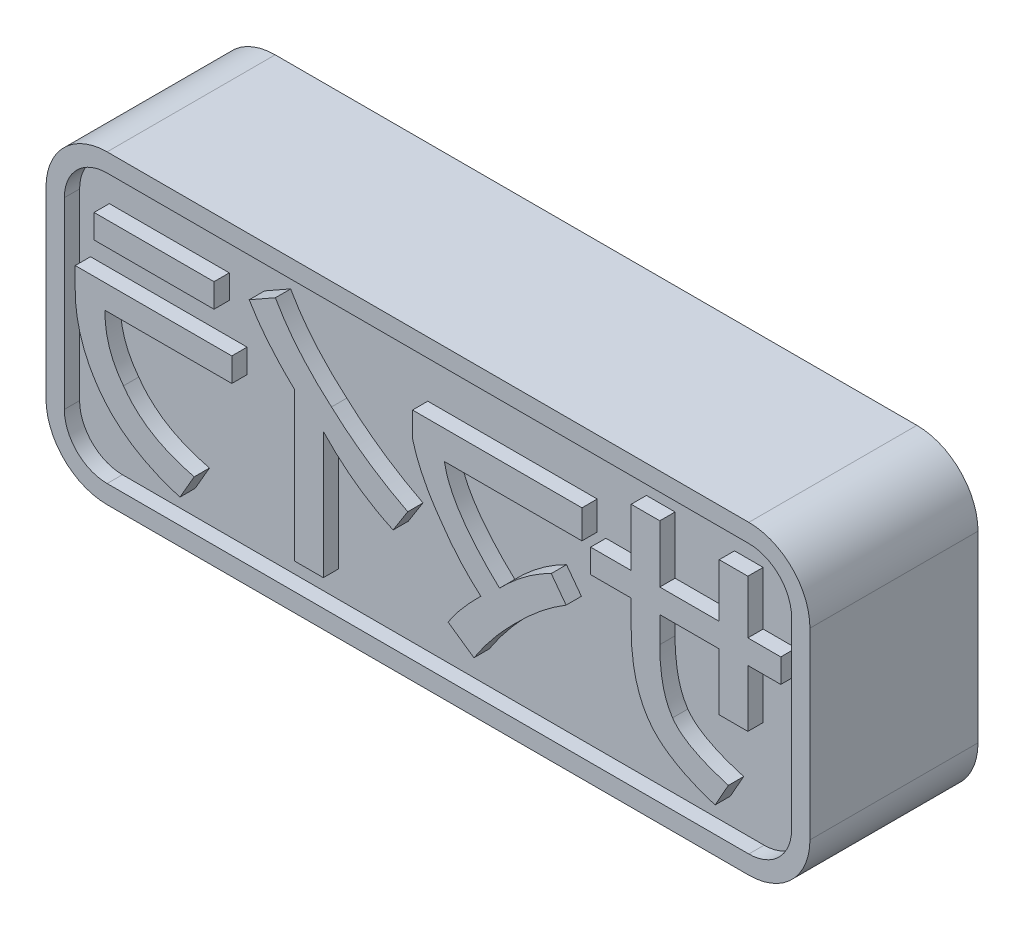
from build123d import *

# Parameters (mm, degrees)
BOSS_EXTRUDE1_DEPTH = 5
BOSS_EXTRUDE2_DEPTH = 0.5
SKETCH3_W           = 3.925243157
SKETCH3_H           = 0.7806506
BOSS_EXTRUDE3_DEPTH = 0.5
SKETCH4_W           = 4
SKETCH4_H           = 4
CUT_EXTRUDE1_DEPTH  = 4


with BuildPart() as part:
    # Sketch1 → Boss-Extrude1 (new body)
    with BuildSketch(Plane.XY):
        with BuildLine():
            Line((-10.5, 5), (10.5, 5))
            ThreePointArc((10.5, 5), (11.914213562, 4.414213562), (12.5, 3))
            Line((12.5, 3), (12.5, -3))
            ThreePointArc((12.5, -3), (11.914213562, -4.414213562), (10.5, -5))
            Line((10.5, -5), (-10.5, -5))
            ThreePointArc((-10.5, -5), (-11.914213562, -4.414213562), (-12.5, -3))
            Line((-12.5, -3), (-12.5, 3))
            ThreePointArc((-12.5, 3), (-11.914213562, 4.414213562), (-10.5, 5))
        make_face()
    extrude(amount=BOSS_EXTRUDE1_DEPTH)

    # Sketch2 → Boss-Extrude2 (add)
    with BuildSketch(Plane.XY.offset(5)):
        with BuildLine():
            Line((10.5, 5), (-10.5, 5))
            ThreePointArc((-10.5, 5), (-11.914213562, 4.414213562), (-12.5, 3))
            Line((-12.5, 3), (-12.5, -3))
            ThreePointArc((-12.5, -3), (-11.914213562, -4.414213562), (-10.5, -5))
            Line((-10.5, -5), (10.5, -5))
            ThreePointArc((10.5, -5), (11.914213562, -4.414213562), (12.5, -3))
            Line((12.5, -3), (12.5, 3))
            ThreePointArc((12.5, 3), (11.914213562, 4.414213562), (10.5, 5))
        make_face()
        with BuildLine():
            Line((10.5, 4.4), (-10.5, 4.4))
            ThreePointArc((-10.5, 4.4), (-11.489949494, 3.989949494), (-11.9, 3))
            Line((-11.9, 3), (-11.9, -3))
            ThreePointArc((-11.9, -3), (-11.489949494, -3.989949494), (-10.5, -4.4))
            Line((-10.5, -4.4), (10.5, -4.4))
            ThreePointArc((10.5, -4.4), (11.489949494, -3.989949494), (11.9, -3))
            Line((11.9, -3), (11.9, 3))
            ThreePointArc((11.9, 3), (11.489949494, 3.989949494), (10.5, 4.4))
        make_face(mode=Mode.SUBTRACT)
    extrude(amount=BOSS_EXTRUDE2_DEPTH)

    # Sketch3 → Boss-Extrude3 (add)
    with BuildSketch(Plane.XY.offset(5)):
        with BuildLine():
            Line((6.649827221, 1.709613878), (5.323087704, 1.709613878))
            Line((5.323087704, 1.709613878), (5.323087704, 0.928963278))
            Line((5.323087704, 0.928963278), (6.649827221, 0.928963278))
            Line((6.649827221, 0.928963278), (6.649827221, 0.077455503))
            add(Edge.make_bspline(
                [(6.649827221, 0.077455503), (6.651376704, -0.04109447), (6.654389008, -0.271563805), (6.680326701, -0.60728573), (6.722849081, -0.922577431), (6.780511342, -1.218488728), (6.857426325, -1.494254078), (6.951751475, -1.7497529), (7.059867372, -1.987100715), (7.150329181, -2.13059508), (7.194694462, -2.200969174)],
                knots=[0, 0, 0, 0, 0.00035561, 0.000691331, 0.00100941, 0.001309617, 0.001595066, 0.001867173, 0.002126226, 0.00237555, 0.00237555, 0.00237555, 0.00237555], degree=3))
            add(Edge.make_bspline(
                [(7.194694462, -2.200969174), (7.244642663, -2.271234317), (7.347224688, -2.415542633), (7.540893795, -2.610859351), (7.766322614, -2.796525633), (8.026697725, -2.970926795), (8.3188806, -3.137490143), (8.647315694, -3.290384525), (9.008785884, -3.43460474), (9.264120724, -3.518522161), (9.396153587, -3.561915603)],
                knots=[0, 0, 0, 0, 0.000258262, 0.000530411, 0.00082198, 0.001133375, 0.001469318, 0.001830002, 0.002219293, 0.002636149, 0.002636149, 0.002636149, 0.002636149], degree=3))
            Line((9.396153587, -3.561915603), (9.83107004, -2.788595056))
            add(Edge.make_bspline(
                [(9.83107004, -2.788595056), (9.717559395, -2.754529617), (9.499669347, -2.689139096), (9.190805721, -2.579792321), (8.914393277, -2.462638286), (8.669226473, -2.340898436), (8.454916696, -2.215006455), (8.273973509, -2.080806813), (8.121241957, -1.942939679), (8.042367052, -1.838964249), (8.004665273, -1.789264554)],
                knots=[0, 0, 0, 0, 0.000355505, 0.000682413, 0.000982388, 0.001255563, 0.001503211, 0.001726781, 0.001930768, 0.002117556, 0.002117556, 0.002117556, 0.002117556], degree=3))
            add(Edge.make_bspline(
                [(8.004665273, -1.789264554), (7.97091344, -1.736591364), (7.90116179, -1.627736773), (7.816284223, -1.445481925), (7.746693078, -1.242249433), (7.68580288, -1.019368833), (7.642365255, -0.774306097), (7.609318914, -0.508888526), (7.589825389, -0.222553891), (7.587865516, -0.024788046), (7.586852275, 0.077455503)],
                knots=[0, 0, 0, 0, 0.000187522, 0.000387534, 0.000601202, 0.000831464, 0.001079945, 0.001347093, 0.001633632, 0.001940334, 0.001940334, 0.001940334, 0.001940334], degree=3))
            Line((7.586852275, 0.077455503), (7.586852275, 0.928963278))
            Line((7.586852275, 0.928963278), (9.53175956, 0.928963278))
            Line((9.53175956, 0.928963278), (9.53175956, -0.94020013))
            Line((9.53175956, -0.94020013), (10.468784615, -0.94020013))
            Line((10.468784615, -0.94020013), (10.468784615, 0.928963278))
            Line((10.468784615, 0.928963278), (11.546302344, 0.928963278))
            Line((11.546302344, 0.928963278), (11.546302344, 1.709613878))
            Line((11.546302344, 1.709613878), (10.468784615, 1.709613878))
            Line((10.468784615, 1.709613878), (10.468784615, 3.457831418))
            Line((10.468784615, 3.457831418), (9.53175956, 3.457831418))
            Line((9.53175956, 3.457831418), (9.53175956, 1.709613878))
            Line((9.53175956, 1.709613878), (7.586852275, 1.709613878))
            Line((7.586852275, 1.709613878), (7.586852275, 3.587329014))
            Line((7.586852275, 3.587329014), (6.649827221, 3.587329014))
            Line((6.649827221, 3.587329014), (6.649827221, 1.709613878))
        make_face()
        with BuildLine():
            Line((-0.505037103, 2.680845844), (-0.505037103, 1.864766657))
            add(Edge.make_bspline(
                [(-0.505037103, 1.864766657), (-0.484267586, 1.789996362), (-0.442260619, 1.63877121), (-0.36316234, 1.413323447), (-0.270101459, 1.18645249), (-0.163873315, 0.957443294), (-0.042059676, 0.727726438), (0.092279384, 0.495778435), (0.239848847, 0.261698262), (0.347810416, 0.108748512), (0.402667741, 0.031031837)],
                knots=[0, 0, 0, 0, 0.000232754, 0.000470752, 0.000716221, 0.000968188, 0.001227762, 0.001495974, 0.001772197, 0.002057539, 0.002057539, 0.002057539, 0.002057539], degree=3))
            add(Edge.make_bspline(
                [(0.402667741, 0.031031837), (0.49958699, -0.109358468), (0.692054565, -0.38815326), (1.01547789, -0.777548328), (1.356949717, -1.145524269), (1.605456588, -1.367994782), (1.729407258, -1.478958995)],
                knots=[0, 0, 0, 0, 0.000511545, 0.001015854, 0.001517132, 0.002015972, 0.002015972, 0.002015972, 0.002015972], degree=3))
            add(Edge.make_bspline(
                [(1.729407258, -1.478958995), (1.670151814, -1.538207794), (1.554682383, -1.653664276), (1.389667665, -1.825538932), (1.237833658, -1.992592168), (1.096933895, -2.152912464), (0.970214915, -2.309628262), (0.854746069, -2.45993165), (0.751886981, -2.604935761), (0.69021137, -2.701614191), (0.660441257, -2.748279767)],
                knots=[0, 0, 0, 0, 0.000251383, 0.000489864, 0.000714705, 0.000928582, 0.001130066, 0.001319189, 0.001497139, 0.001663179, 0.001663179, 0.001663179, 0.001663179], degree=3))
            Line((0.660441257, -2.748279767), (1.504618979, -3.335905649))
            add(Edge.make_bspline(
                [(1.504618979, -3.335905649), (1.597431175, -3.196669156), (1.784965099, -2.915331497), (2.100880543, -2.509948678), (2.442766783, -2.109416968), (2.691019742, -1.854692366), (2.816698391, -1.725737432)],
                knots=[0, 0, 0, 0, 0.000501847, 0.001014019, 0.001540744, 0.002080809, 0.002080809, 0.002080809, 0.002080809], degree=3))
            add(Edge.make_bspline(
                [(2.816698391, -1.725737432), (2.885903369, -1.654856266), (3.022721921, -1.514723882), (3.233111214, -1.314405094), (3.444953238, -1.125033935), (3.656563471, -0.944846947), (3.871708683, -0.778290181), (4.084531698, -0.618039734), (4.301380835, -0.471677402), (4.448158901, -0.38061975), (4.520935616, -0.335470792)],
                knots=[0, 0, 0, 0, 0.000297171, 0.000587509, 0.000871279, 0.001149556, 0.001421071, 0.001687399, 0.001948646, 0.00220557, 0.00220557, 0.00220557, 0.00220557], degree=3))
            Line((4.520935616, -0.335470792), (4.034708795, 0.316903887))
            add(Edge.make_bspline(
                [(4.034708795, 0.316903887), (3.960953536, 0.280292652), (3.812480075, 0.206592187), (3.595874947, 0.079191127), (3.380980234, -0.060254724), (3.167389712, -0.211308698), (2.956564018, -0.375523874), (2.749279624, -0.553511767), (2.541937549, -0.742220943), (2.408877284, -0.876870855), (2.341466649, -0.945086832)],
                knots=[0, 0, 0, 0, 0.00024696, 0.000497144, 0.000753323, 0.001015346, 0.001281716, 0.001554686, 0.001834836, 0.002122501, 0.002122501, 0.002122501, 0.002122501], degree=3))
            add(Edge.make_bspline(
                [(2.341466649, -0.945086832), (2.276016434, -0.883085452), (2.147013849, -0.760880533), (1.962205036, -0.575814487), (1.788155766, -0.393434343), (1.625466074, -0.213909636), (1.474266243, -0.03681547), (1.332913411, 0.136905176), (1.203288495, 0.308588472), (1.08669648, 0.479157297), (0.977539919, 0.644751775), (0.883510164, 0.810275163), (0.796555878, 0.970973726), (0.723892617, 1.130719051), (0.65927171, 1.286598619), (0.608325375, 1.441122312), (0.56701504, 1.592722364), (0.548571817, 1.693986077), (0.53949539, 1.74382079)],
                knots=[0, 0, 0, 0, 0.000270454, 0.000533066, 0.000784521, 0.001026702, 0.001259786, 0.001483019, 0.001698522, 0.001904899, 0.002102795, 0.002293271, 0.002475804, 0.002650721, 0.002819507, 0.002981765, 0.003138525, 0.003290426, 0.003290426, 0.003290426, 0.003290426], degree=3))
            Line((0.53949539, 1.74382079), (5.038925998, 1.74382079))
            Line((5.038925998, 1.74382079), (5.038925998, 2.680845844))
            Line((5.038925998, 2.680845844), (-0.505037103, 2.680845844))
        make_face()
        with BuildLine():
            add(Edge.make_bspline(
                [(-3.156805792, 1.442066958), (-3.25522625, 1.528869115), (-3.44955869, 1.700261074), (-3.724710935, 1.966366833), (-3.982469619, 2.234734149), (-4.221946475, 2.505257924), (-4.442354268, 2.779355028), (-4.643865171, 3.056176701), (-4.829971174, 3.333701677), (-4.93910268, 3.524761156), (-4.992983963, 3.619092575)],
                knots=[0, 0, 0, 0, 0.000393647, 0.000777261, 0.001147936, 0.001509725, 0.001860786, 0.00220264, 0.002536729, 0.002862541, 0.002862541, 0.002862541, 0.002862541], degree=3))
            Line((-4.992983963, 3.619092575), (-5.84937844, 3.134087429))
            add(Edge.make_bspline(
                [(-5.84937844, 3.134087429), (-5.804009534, 3.058345693), (-5.712030283, 2.904789684), (-5.559841151, 2.678613895), (-5.393363342, 2.452888576), (-5.214049139, 2.226795409), (-5.019919277, 2.001906345), (-4.814021153, 1.776001926), (-4.593713476, 1.550511754), (-4.438849934, 1.404081361), (-4.36015609, 1.329672819)],
                knots=[0, 0, 0, 0, 0.000264836, 0.000536919, 0.000817428, 0.001106101, 0.001402392, 0.001708508, 0.002022971, 0.002347854, 0.002347854, 0.002347854, 0.002347854], degree=3))
            Line((-4.36015609, 1.329672819), (-4.36015609, -3.530152042))
            Line((-4.36015609, -3.530152042), (-3.423131035, -3.530152042))
            Line((-3.423131035, -3.530152042), (-3.423131035, 0.613771017))
            add(Edge.make_bspline(
                [(-3.423131035, 0.613771017), (-3.338844608, 0.526605486), (-3.171213317, 0.353248151), (-2.906413817, 0.109258186), (-2.634244356, -0.120920355), (-2.352914121, -0.33503908), (-2.062185779, -0.533377152), (-1.763523465, -0.717466358), (-1.456643922, -0.887474309), (-1.245458606, -0.986951892), (-1.139819657, -1.036712489)],
                knots=[0, 0, 0, 0, 0.000363692, 0.000723322, 0.001079651, 0.001432724, 0.001783438, 0.00213503, 0.002484961, 0.002835198, 0.002835198, 0.002835198, 0.002835198], degree=3))
            Line((-1.139819657, -1.036712489), (-0.662144563, -0.280495398))
            add(Edge.make_bspline(
                [(-0.662144563, -0.280495398), (-0.777016191, -0.220218246), (-1.0059522, -0.100087531), (-1.340219824, 0.093802171), (-1.666475713, 0.29492891), (-1.983409141, 0.505102353), (-2.290472502, 0.725404632), (-2.588232721, 0.95540031), (-2.878376554, 1.192775752), (-3.064152811, 1.359110249), (-3.156805792, 1.442066958)],
                knots=[0, 0, 0, 0, 0.00038914, 0.000775545, 0.001158991, 0.001538822, 0.001916162, 0.002292469, 0.002667414, 0.003040466, 0.003040466, 0.003040466, 0.003040466], degree=3))
        make_face()
        with Locations((-8.964772954, 2.679013331)):
            Rectangle(SKETCH3_W, SKETCH3_H)
        with BuildLine():
            Line((-6.419412195, 1.256372293), (-11.543118949, 1.256372293))
            Line((-11.543118949, 1.256372293), (-11.543118949, 0.562460649))
            add(Edge.make_bspline(
                [(-11.543118949, 0.562460649), (-11.541283624, 0.455249927), (-11.537644518, 0.24267116), (-11.500082152, -0.072002736), (-11.443837031, -0.380312494), (-11.360659544, -0.681258927), (-11.257542506, -0.976198436), (-11.129313417, -1.263612185), (-10.977880954, -1.544065485), (-10.860691672, -1.723275042), (-10.801561963, -1.813698063)],
                knots=[0, 0, 0, 0, 0.000321489, 0.000637452, 0.000949422, 0.001260901, 0.001573101, 0.001885936, 0.002204081, 0.00252809, 0.00252809, 0.00252809, 0.00252809], degree=3))
            add(Edge.make_bspline(
                [(-10.801561963, -1.813698063), (-10.765414276, -1.864570608), (-10.693011277, -1.966467164), (-10.575072737, -2.112836079), (-10.4508165, -2.255122618), (-10.31738937, -2.390469704), (-10.176392422, -2.520117883), (-10.028288789, -2.645190821), (-9.87215004, -2.764645083), (-9.707759592, -2.878635311), (-9.535460809, -2.986957021), (-9.356099088, -3.091137757), (-9.168576796, -3.188462919), (-8.974281089, -3.282037843), (-8.771201997, -3.367981136), (-8.560938009, -3.450480226), (-8.342228141, -3.525862836), (-8.193013581, -3.571710931), (-8.117541043, -3.59490084)],
                knots=[0, 0, 0, 0, 0.000187184, 0.000374925, 0.000563633, 0.000753689, 0.000944759, 0.001138097, 0.00133504, 0.001534308, 0.00173801, 0.001945457, 0.002156383, 0.002371679, 0.002592248, 0.002817755, 0.003049182, 0.003286039, 0.003286039, 0.003286039, 0.003286039], degree=3))
            Line((-8.117541043, -3.59490084), (-7.649639353, -2.78493003))
            add(Edge.make_bspline(
                [(-7.649639353, -2.78493003), (-7.777626541, -2.752149049), (-8.027668386, -2.688106569), (-8.385126428, -2.563545982), (-8.715109245, -2.416066931), (-9.019964798, -2.250515549), (-9.29794711, -2.06192875), (-9.547358294, -1.850108549), (-9.774822716, -1.621269671), (-9.901540083, -1.449671019), (-9.964714293, -1.364121505)],
                knots=[0, 0, 0, 0, 0.000396234, 0.000774101, 0.001133948, 0.00147949, 0.001813595, 0.002139579, 0.002460098, 0.002778757, 0.002778757, 0.002778757, 0.002778757], degree=3))
            add(Edge.make_bspline(
                [(-9.964714293, -1.364121505), (-10.015216035, -1.29572471), (-10.114986609, -1.160600905), (-10.241800206, -0.945488721), (-10.349173118, -0.724698976), (-10.43470937, -0.49681046), (-10.499842516, -0.26256382), (-10.543590815, -0.022159869), (-10.567851092, 0.224767255), (-10.56647517, 0.391375696), (-10.565778605, 0.475721693)],
                knots=[0, 0, 0, 0, 0.000254921, 0.000503618, 0.000747858, 0.000990649, 0.001232806, 0.00147626, 0.001722911, 0.00197581, 0.00197581, 0.00197581, 0.00197581], degree=3))
            Line((-10.565778605, 0.475721693), (-6.419412195, 0.475721693))
            Line((-6.419412195, 0.475721693), (-6.419412195, 1.256372293))
        make_face()
    extrude(amount=BOSS_EXTRUDE3_DEPTH)

    # Sketch4 → Cut-Extrude1 (cut)
    with BuildSketch(Plane(origin=(0, 0, 0), x_dir=(-1, 0, 0), z_dir=(0, 0, -1))):
        Rectangle(SKETCH4_W, SKETCH4_H)
    extrude(amount=-CUT_EXTRUDE1_DEPTH, mode=Mode.SUBTRACT)


solid = part.part
